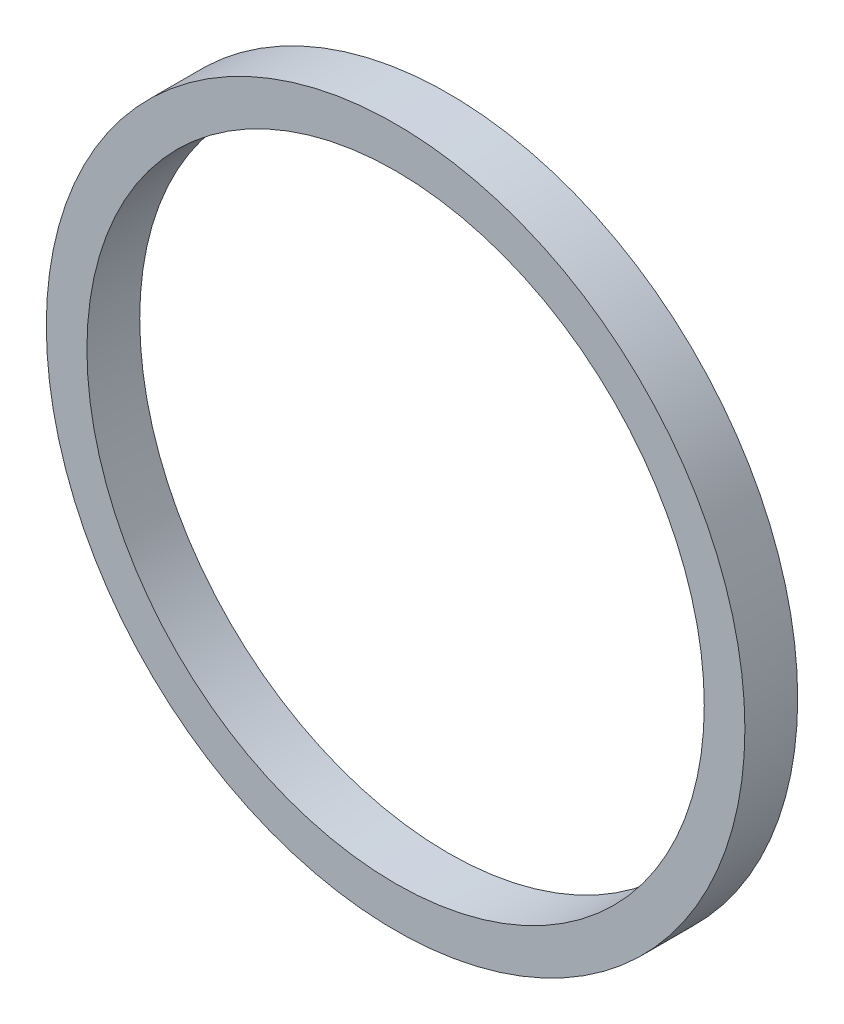
from build123d import *

# Parameters (mm, degrees)
SKETCH1_R           = 86
SKETCH1_R_2         = 76
BOSS_EXTRUDE1_DEPTH = 13


with BuildPart() as part:
    # Sketch1 → Boss-Extrude1 (new body)
    with BuildSketch(Plane.XY):
        Circle(SKETCH1_R)
        Circle(SKETCH1_R_2, mode=Mode.SUBTRACT)
    extrude(amount=BOSS_EXTRUDE1_DEPTH)


solid = part.part
